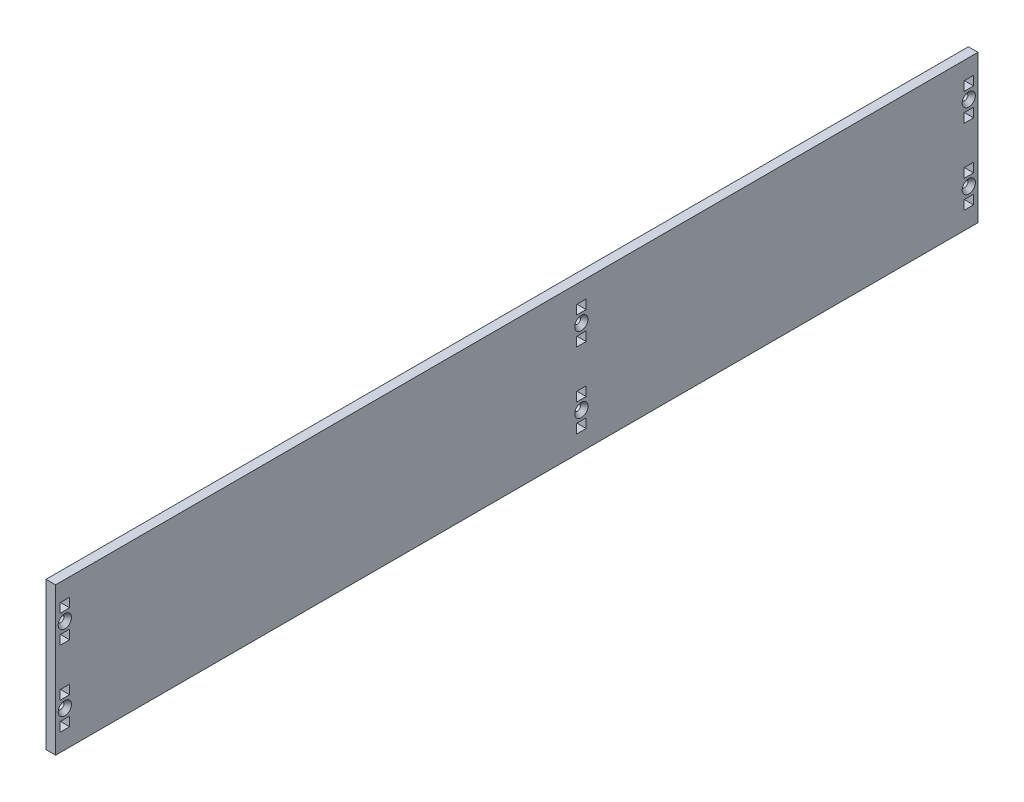
from build123d import *

# Parameters (mm, degrees)
SKETCH1_W                                         = 635
SKETCH1_H                                         = 101.6
SKETCH1_R                                         = 2.15265
SKETCH1_W_2                                       = 6.604
SKETCH1_H_2                                       = 6.35
BOSS_EXTRUDE1_DEPTH                               = 6.604
CSK_FOR_8_FLAT_HEAD_SOCKET_CAP_SCREW1_D           = 4.3053
CSK_FOR_8_FLAT_HEAD_SOCKET_CAP_SCREW1_CSINK_D     = 9.1186
CSK_FOR_8_FLAT_HEAD_SOCKET_CAP_SCREW1_CSINK_ANGLE = 82


with BuildPart() as part:
    # Sketch1 → Boss-Extrude1 (new body)
    with BuildSketch(Plane(origin=(0, 0, 0), x_dir=(0, 0, -1), z_dir=(1, 0, 0))):
        with Locations((-44.45, 0)):
            Rectangle(SKETCH1_W, SKETCH1_H)
        with Locations((-355.6, 25.9207)):
            Circle(SKETCH1_R, mode=Mode.SUBTRACT)
        with Locations((-355.6, -25.9207)):
            Circle(SKETCH1_R, mode=Mode.SUBTRACT)
        with Locations((0, -25.9207)):
            Circle(SKETCH1_R, mode=Mode.SUBTRACT)
        with Locations((0, 25.9207)):
            Circle(SKETCH1_R, mode=Mode.SUBTRACT)
        with Locations((266.7, -25.9207)):
            Circle(SKETCH1_R, mode=Mode.SUBTRACT)
        with Locations((266.7, 25.9207)):
            Circle(SKETCH1_R, mode=Mode.SUBTRACT)
        with Locations((-355.6, 16.3957)):
            Rectangle(SKETCH1_W_2, SKETCH1_H_2, mode=Mode.SUBTRACT)
        with Locations((-355.6, 35.4457)):
            Rectangle(SKETCH1_W_2, SKETCH1_H_2, mode=Mode.SUBTRACT)
        with Locations((-355.6, -35.4457)):
            Rectangle(SKETCH1_W_2, SKETCH1_H_2, mode=Mode.SUBTRACT)
        with Locations((-355.6, -16.3957)):
            Rectangle(SKETCH1_W_2, SKETCH1_H_2, mode=Mode.SUBTRACT)
        with Locations((0, -16.3957)):
            Rectangle(SKETCH1_W_2, SKETCH1_H_2, mode=Mode.SUBTRACT)
        with Locations((0, -35.4457)):
            Rectangle(SKETCH1_W_2, SKETCH1_H_2, mode=Mode.SUBTRACT)
        with Locations((0, 35.4457)):
            Rectangle(SKETCH1_W_2, SKETCH1_H_2, mode=Mode.SUBTRACT)
        with Locations((0, 16.3957)):
            Rectangle(SKETCH1_W_2, SKETCH1_H_2, mode=Mode.SUBTRACT)
        with Locations((266.7, -16.3957)):
            Rectangle(SKETCH1_W_2, SKETCH1_H_2, mode=Mode.SUBTRACT)
        with Locations((266.7, -35.4457)):
            Rectangle(SKETCH1_W_2, SKETCH1_H_2, mode=Mode.SUBTRACT)
        with Locations((266.7, 35.4457)):
            Rectangle(SKETCH1_W_2, SKETCH1_H_2, mode=Mode.SUBTRACT)
        with Locations((266.7, 16.3957)):
            Rectangle(SKETCH1_W_2, SKETCH1_H_2, mode=Mode.SUBTRACT)
    extrude(amount=BOSS_EXTRUDE1_DEPTH)

    # CSK for #8 Flat Head Socket Cap Screw1 (through all)
    with Locations(Plane(origin=(6.604, 0, 0), x_dir=(0, 0, -1), z_dir=(1, 0, 0))):
        with Locations((-355.6, 25.9207), (-355.6, -25.9207), (0, 25.9207), (0, -25.9207), (266.7, 25.9207), (266.7, -25.9207)):
            CounterSinkHole(CSK_FOR_8_FLAT_HEAD_SOCKET_CAP_SCREW1_D / 2, CSK_FOR_8_FLAT_HEAD_SOCKET_CAP_SCREW1_CSINK_D / 2, counter_sink_angle=CSK_FOR_8_FLAT_HEAD_SOCKET_CAP_SCREW1_CSINK_ANGLE)


solid = part.part
